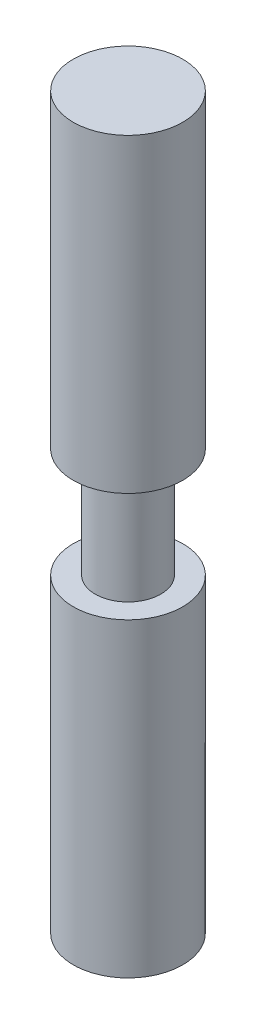
from build123d import *

# Parameters (mm, degrees)
SKETCH1_R           = 5.715
BOSS_EXTRUDE1_DEPTH = 19.05
SKETCH2_R           = 9.525
BOSS_EXTRUDE2_DEPTH = 53.975
SKETCH3_R           = 9.525
BOSS_EXTRUDE3_DEPTH = 53.975


with BuildPart() as part:
    # Sketch1 → Boss-Extrude1 (new body)
    with BuildSketch(Plane(origin=(0, 0, 0), x_dir=(1, 0, 0), z_dir=(0, 1, 0))):
        Circle(SKETCH1_R)
    extrude(amount=BOSS_EXTRUDE1_DEPTH)

    # Sketch2 → Boss-Extrude2 (add)
    with BuildSketch(Plane(origin=(0, 19.05, 0), x_dir=(1, 0, 0), z_dir=(0, 1, 0))):
        Circle(SKETCH2_R)
    extrude(amount=BOSS_EXTRUDE2_DEPTH)

    # Sketch3 → Boss-Extrude3 (add)
    with BuildSketch(Plane.XZ):
        Circle(SKETCH3_R)
    extrude(amount=BOSS_EXTRUDE3_DEPTH)


solid = part.part
